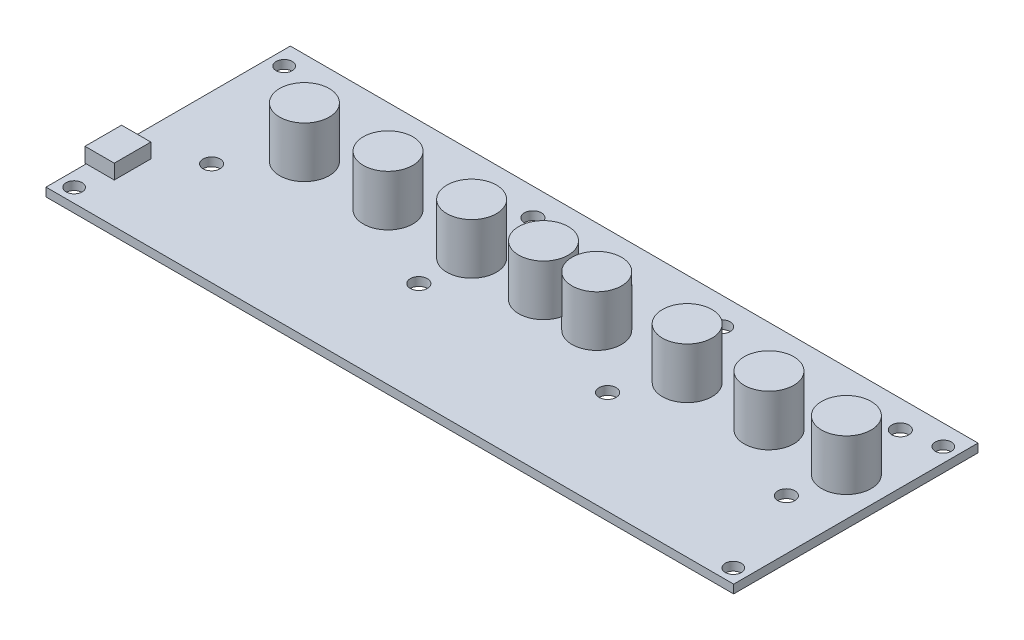
from build123d import *

# Parameters (mm, degrees)
SKETCH1_W               = 141
SKETCH1_H               = 50.1
BOSS_EXTRUDE1_DEPTH     = 0.875
SKETCH3_R               = 1.651
CUT_EXTRUDE1_DEPTH      = 1.875
SKETCH4_R               = 1.75
CUT_EXTRUDE2_DEPTH      = 1.875
CUT_EXTRUDE2_DEPTH_BACK = 1.875
SKETCH2_R               = 5.08
BOSS_EXTRUDE2_DEPTH     = 10.414
BOSS_EXTRUDE3_START     = 0.254
SKETCH5_W               = 7.5
SKETCH5_H               = 3
BOSS_EXTRUDE3_DEPTH     = 6


with BuildPart() as part:
    # Sketch1 → Boss-Extrude1 (new body, symmetric)
    with BuildSketch(Plane(origin=(0, 0, 0), x_dir=(1, 0, 0), z_dir=(0, 1, 0))):
        Rectangle(SKETCH1_W, SKETCH1_H)
    extrude(amount=BOSS_EXTRUDE1_DEPTH, both=True)

    # Sketch3 → Cut-Extrude1 (cut, symmetric)
    with BuildSketch(Plane(origin=(0, 0, 0), x_dir=(1, 0, 0), z_dir=(0, 1, 0))):
        with Locations((67.579, 20.859)):
            Circle(SKETCH3_R)
        with Locations((67.579, -22.199)):
            Circle(SKETCH3_R)
    cut_extrude1 = extrude(amount=CUT_EXTRUDE1_DEPTH, both=True, mode=Mode.SUBTRACT)

    # Sketch4 → Cut-Extrude2 (cut, two sides)
    with BuildSketch(Plane(origin=(0, 0, 0), x_dir=(1, 0, 0), z_dir=(0, 1, 0))) as cut_extrude2_sk:
        with Locations((-57.65, 19.425)):
            Circle(SKETCH4_R)
        with Locations((-15.15, 19.425)):
            Circle(SKETCH4_R)
        with Locations((23.55, 19.425)):
            Circle(SKETCH4_R)
        with Locations((60.2, 19.425)):
            Circle(SKETCH4_R)
        with Locations((-15.15, -3.95)):
            Circle(SKETCH4_R)
        with Locations((23.55, -3.95)):
            Circle(SKETCH4_R)
        with Locations((60.2, -3.95)):
            Circle(SKETCH4_R)
        with Locations((-57.65, -3.95)):
            Circle(SKETCH4_R)
    extrude(amount=CUT_EXTRUDE2_DEPTH, mode=Mode.SUBTRACT)
    extrude(cut_extrude2_sk.sketch, amount=-CUT_EXTRUDE2_DEPTH_BACK, mode=Mode.SUBTRACT)

    # Mirror1: Cut-Extrude1 across plane
    add(cut_extrude1.mirror(Plane(origin=(0, 0, 0), x_dir=(0, 0, 1), z_dir=(1, 0, 0))), mode=Mode.SUBTRACT)

    # Sketch2 → Boss-Extrude2 (add)
    with BuildSketch(Plane(origin=(0, 0.875, 0), x_dir=(1, 0, 0), z_dir=(0, 1, 0))):
        with Locations((-48.5625, 6)):
            Circle(SKETCH2_R)
        with Locations((-31.4175, 6)):
            Circle(SKETCH2_R)
        with Locations((-14.2725, 6)):
            Circle(SKETCH2_R)
        with Locations((0.4595, 6)):
            Circle(SKETCH2_R)
        with Locations((11.3815, 6)):
            Circle(SKETCH2_R)
        with Locations((29.9235, 6)):
            Circle(SKETCH2_R)
        with Locations((46.6875, 6)):
            Circle(SKETCH2_R)
        with Locations((62.5625, 6)):
            Circle(SKETCH2_R)
    extrude(amount=BOSS_EXTRUDE2_DEPTH)

    # Sketch5 → Boss-Extrude3 (add)
    with BuildSketch(Plane.ZY.offset(70.5).offset(BOSS_EXTRUDE3_START)):
        with Locations((13.05, 2.375)):
            Rectangle(SKETCH5_W, SKETCH5_H)
    extrude(amount=-BOSS_EXTRUDE3_DEPTH)


solid = part.part
